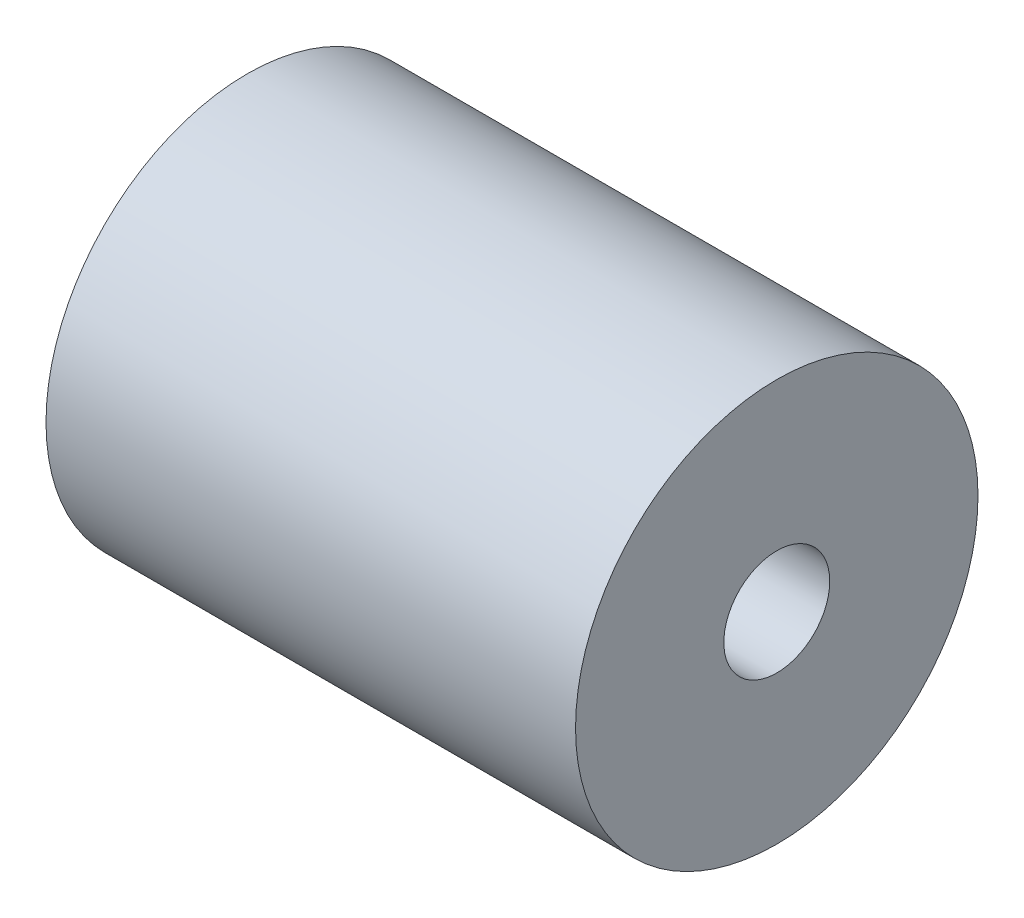
from build123d import *

# Parameters (mm, degrees)
SKETCH1_R           = 9.5
BOSS_EXTRUDE1_DEPTH = 25
SKETCH2_R           = 2.5
CUT_EXTRUDE1_DEPTH  = 12.5
SKETCH3_R           = 4
CUT_EXTRUDE2_DEPTH  = 12.5


with BuildPart() as part:
    # Sketch1 → Boss-Extrude1 (new body)
    with BuildSketch(Plane(origin=(0, 0, 0), x_dir=(0, 0, -1), z_dir=(1, 0, 0))):
        Circle(SKETCH1_R)
    extrude(amount=BOSS_EXTRUDE1_DEPTH)

    # Sketch2 → Cut-Extrude1 (cut)
    with BuildSketch(Plane(origin=(25, 0, 0), x_dir=(0, 0, -1), z_dir=(1, 0, 0))):
        Circle(SKETCH2_R)
    extrude(amount=-CUT_EXTRUDE1_DEPTH, mode=Mode.SUBTRACT)

    # Sketch3 → Cut-Extrude2 (cut)
    with BuildSketch(Plane.ZY):
        Circle(SKETCH3_R)
    extrude(amount=-CUT_EXTRUDE2_DEPTH, mode=Mode.SUBTRACT)


solid = part.part
